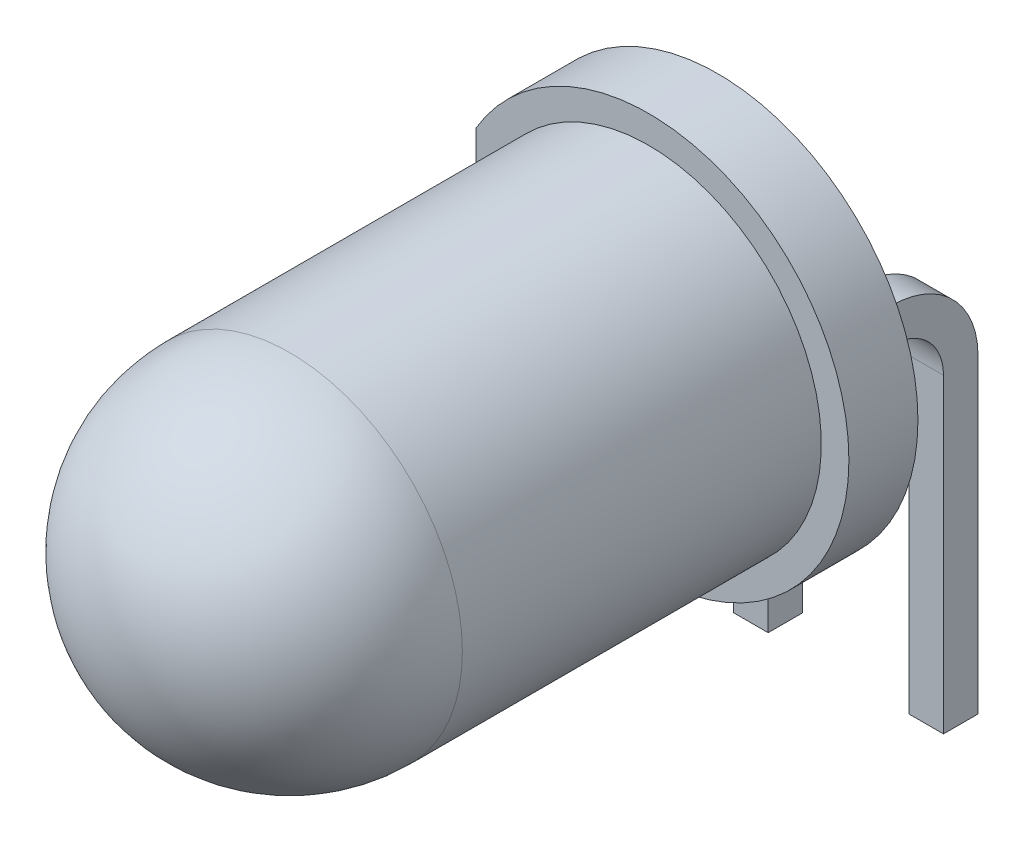
from build123d import *

# Parameters (mm, degrees)
ESQUISSE3_R                  = 2.9
BOSS_EXTRU_1_DEPTH           = 1
ENL_V_MAT_EXTRU_1_DEPTH      = 8.7000001
ENL_V_MAT_EXTRU_1_DEPTH_BACK = 2
ESQUISSE7_W                  = 0.5
ESQUISSE7_H                  = 0.5


with BuildPart() as part:
    # Esquisse3 → Boss.-Extru.1 (new body)
    with BuildSketch(Plane.XY):
        Circle(ESQUISSE3_R)
    extrude(amount=BOSS_EXTRU_1_DEPTH)

    # Esquisse5 → Révolution1 (revolve)
    with BuildSketch(Plane(origin=(0, 0, 0), x_dir=(1, 0, 0), z_dir=(0, 1, 0))):
        with BuildLine():
            Line((0, -1), (0, -8.7))
            ThreePointArc((0, -8.7), (1.767766953, -7.96776677), (2.5, -6.199999817))
            Line((2.5, -6.199999817), (2.5, -1))
            Line((2.5, -1), (0, -1))
        make_face()
    revolve(axis=Axis((0, 0, 1), (0, 0, 1)))

    # Esquisse6 → Enlèv. mat.-Extru.1 (cut, two sides)
    with BuildSketch(Plane.XY.offset(1)) as enl_v_mat_extru_1_sk:
        Polygon((-2.5, 25.362745966), (-2.5, 1.469693846), (-2.5, -1.469693846), (-2.5, -25.362745966), (-50.286104241, -25.362745966), (-50.286104241, 25.362745966), align=None)
    extrude(amount=ENL_V_MAT_EXTRU_1_DEPTH, mode=Mode.SUBTRACT)
    extrude(enl_v_mat_extru_1_sk.sketch, amount=-ENL_V_MAT_EXTRU_1_DEPTH_BACK, mode=Mode.SUBTRACT)

    # Balayage1: sweep along a path in Esquisse8
    with BuildLine(Plane(origin=(0, 0, 0), x_dir=(0, 0, -1), z_dir=(1, 0, 0))) as balayage1_path:
        Line((0, 0), (1, 0))
        ThreePointArc((1, 0), (1.707106781, -0.292893219), (2, -1))
        Line((2, -1), (2, -5.5))
    # Esquisse7 → Balayage1 (sweep)
    with BuildSketch(Plane.XY):
        with Locations((1.27, 0)):
            Rectangle(ESQUISSE7_W, ESQUISSE7_H)
        with Locations((-1.27, 0)):
            Rectangle(ESQUISSE7_W, ESQUISSE7_H)
    sweep(path=balayage1_path.line)


solid = part.part
